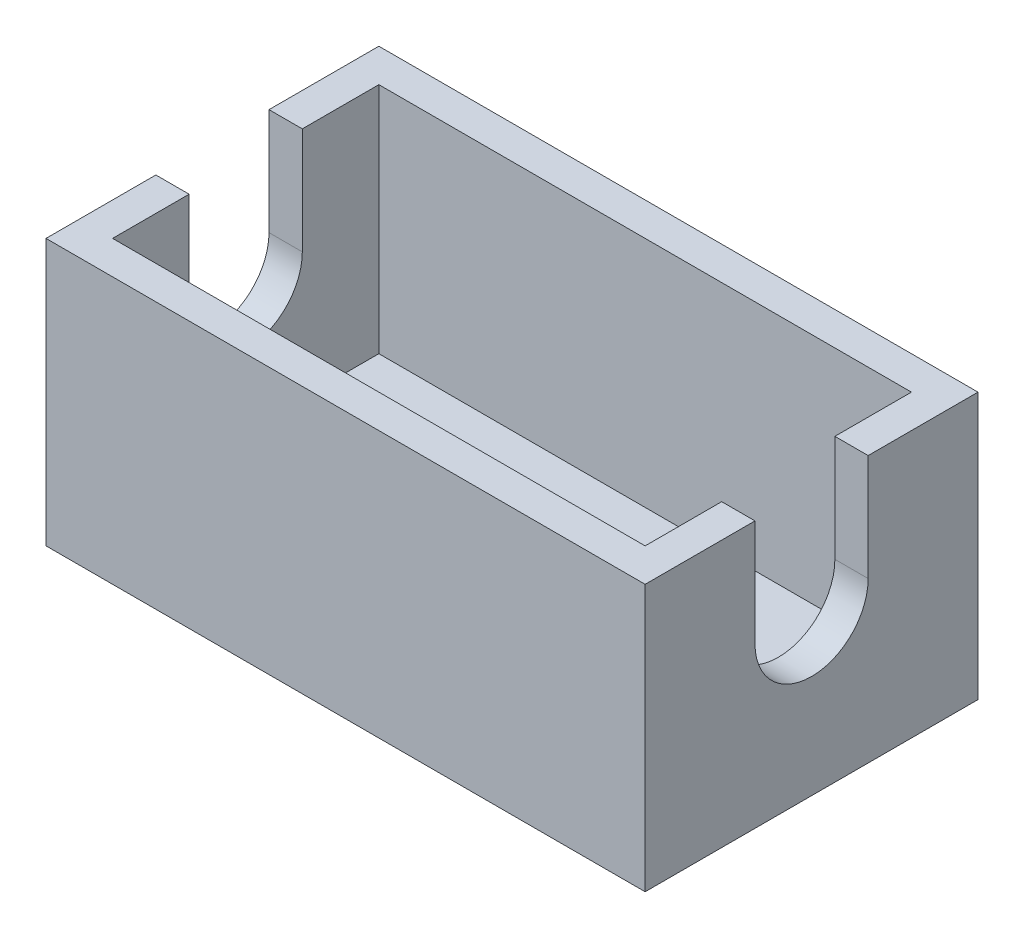
from build123d import *

# Parameters (mm, degrees)
SKETCH1_W           = 45
SKETCH1_H           = 25
BOSS_EXTRUDE1_DEPTH = 2.5
SKETCH2_W           = 45
SKETCH2_H           = 25
SKETCH2_W_2         = 40
SKETCH2_H_2         = 20
BOSS_EXTRUDE2_DEPTH = 17.5
CUT_EXTRUDE1_DEPTH  = 46


with BuildPart() as part:
    # Sketch1 → Boss-Extrude1 (new body)
    with BuildSketch(Plane(origin=(0, 0, 0), x_dir=(1, 0, 0), z_dir=(0, 1, 0))):
        Rectangle(SKETCH1_W, SKETCH1_H)
    extrude(amount=BOSS_EXTRUDE1_DEPTH)

    # Sketch2 → Boss-Extrude2 (add)
    with BuildSketch(Plane(origin=(0, 2.5, 0), x_dir=(1, 0, 0), z_dir=(0, 1, 0))):
        Rectangle(SKETCH2_W, SKETCH2_H)
        Rectangle(SKETCH2_W_2, SKETCH2_H_2, mode=Mode.SUBTRACT)
    extrude(amount=BOSS_EXTRUDE2_DEPTH)

    # Sketch3 → Cut-Extrude1 (cut, through all)
    with BuildSketch(Plane(origin=(22.5, 0, 0), x_dir=(0, 0, -1), z_dir=(1, 0, 0))):
        with BuildLine():
            Line((-4.25, 12), (-4.25, 20))
            Line((-4.25, 20), (4.25, 20))
            Line((4.25, 20), (4.25, 12))
            ThreePointArc((4.25, 12), (0, 7.75), (-4.25, 12))
        make_face()
    extrude(amount=-CUT_EXTRUDE1_DEPTH, mode=Mode.SUBTRACT)


solid = part.part
